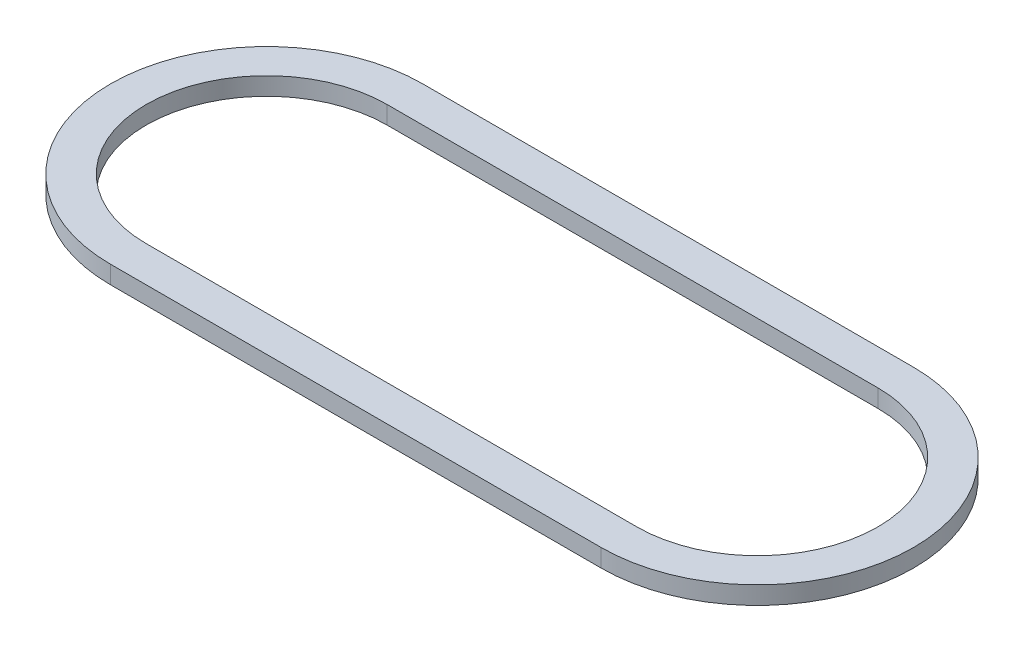
from build123d import *

# Parameters (mm, degrees)
BOSS_EXTRUDE1_DEPTH = 0.508


with BuildPart() as part:
    # Sketch1 → Boss-Extrude1 (new body)
    with BuildSketch(Plane(origin=(0, 0, 0), x_dir=(1, 0, 0), z_dir=(0, 1, 0))):
        with BuildLine():
            Line((-6.985, 4.445), (6.985, 4.445))
            ThreePointArc((6.985, 4.445), (11.43, 0), (6.985, -4.445))
            Line((6.985, -4.445), (-6.985, -4.445))
            ThreePointArc((-6.985, -4.445), (-11.43, 0), (-6.985, 4.445))
        make_face()
        with BuildLine():
            Line((-6.985, 3.429), (6.985, 3.429))
            ThreePointArc((6.985, 3.429), (10.414, 0), (6.985, -3.429))
            Line((6.985, -3.429), (-6.985, -3.429))
            ThreePointArc((-6.985, -3.429), (-10.414, 0), (-6.985, 3.429))
        make_face(mode=Mode.SUBTRACT)
    extrude(amount=BOSS_EXTRUDE1_DEPTH)


solid = part.part
